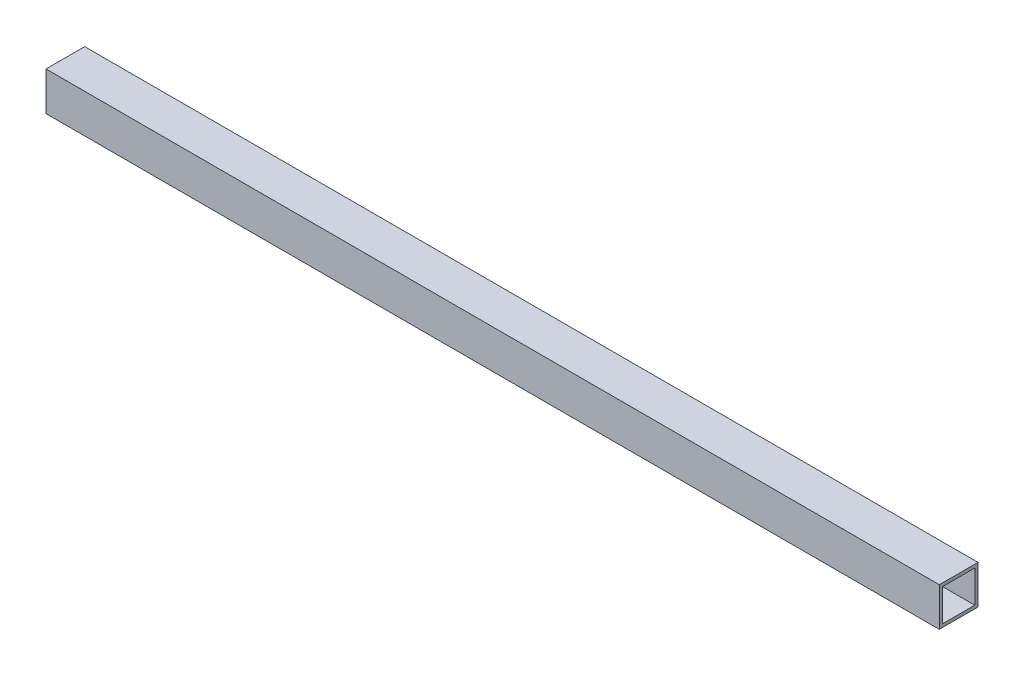
from build123d import *

# Parameters (mm, degrees)
SKETCH1_W           = 19.05
SKETCH1_H           = 19.05
SKETCH1_W_2         = 15.875
SKETCH1_H_2         = 15.875
BOSS_EXTRUDE1_DEPTH = 440


with BuildPart() as part:
    # Sketch1 → Boss-Extrude1 (new body)
    with BuildSketch(Plane(origin=(0, 0, 0), x_dir=(0, 0, -1), z_dir=(1, 0, 0))):
        Rectangle(SKETCH1_W, SKETCH1_H)
        Rectangle(SKETCH1_W_2, SKETCH1_H_2, mode=Mode.SUBTRACT)
    extrude(amount=BOSS_EXTRUDE1_DEPTH)


solid = part.part
